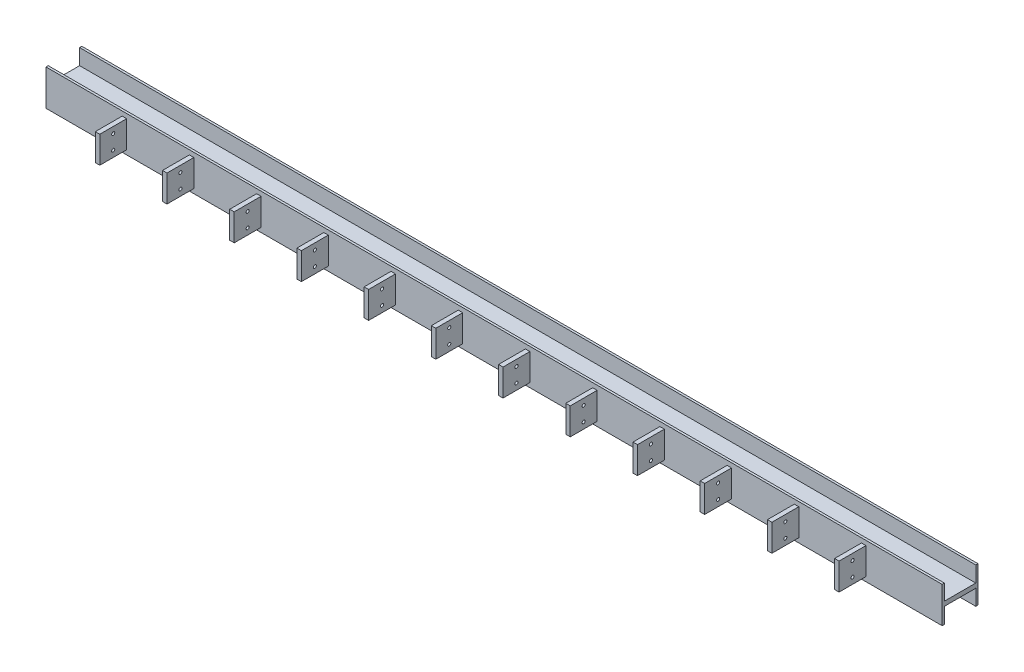
from build123d import *

# Parameters (mm, degrees)
SKETCH1_W           = 10000
SKETCH1_H           = 400
BOSS_EXTRUDE1_DEPTH = 400
SKETCH2_W           = 350
SKETCH2_H           = 175
CUT_EXTRUDE1_DEPTH  = 10100
SKETCH3_W           = 50
SKETCH3_H           = 300
BOSS_EXTRUDE2_DEPTH = 300
SKETCH4_R           = 17.5
CUT_EXTRUDE2_DEPTH  = 8530


with BuildPart() as part:
    # Sketch1 → Boss-Extrude1 (new body)
    with BuildSketch(Plane.XY):
        Rectangle(SKETCH1_W, SKETCH1_H)
    extrude(amount=BOSS_EXTRUDE1_DEPTH)

    # Sketch2 → Cut-Extrude1 (cut)
    with BuildSketch(Plane(origin=(5000, 0, 0), x_dir=(0, 0, -1), z_dir=(1, 0, 0))):
        with Locations((-200, 112.5)):
            Rectangle(SKETCH2_W, SKETCH2_H)
        with Locations((-200, -112.5)):
            Rectangle(SKETCH2_W, SKETCH2_H)
    extrude(amount=-CUT_EXTRUDE1_DEPTH, mode=Mode.SUBTRACT)

    # Sketch3 → Boss-Extrude2 (add)
    with BuildSketch(Plane.XY.offset(400)):
        with Locations((-3375, 0)):
            Rectangle(SKETCH3_W, SKETCH3_H)
        with Locations((-4125, 0)):
            Rectangle(SKETCH3_W, SKETCH3_H)
        with Locations((-2625, 0)):
            Rectangle(SKETCH3_W, SKETCH3_H)
        with Locations((-1875, 0)):
            Rectangle(SKETCH3_W, SKETCH3_H)
        with Locations((-1125, 0)):
            Rectangle(SKETCH3_W, SKETCH3_H)
        with Locations((-375, 0)):
            Rectangle(SKETCH3_W, SKETCH3_H)
        with Locations((375, 0)):
            Rectangle(SKETCH3_W, SKETCH3_H)
        with Locations((1125, 0)):
            Rectangle(SKETCH3_W, SKETCH3_H)
        with Locations((1875, 0)):
            Rectangle(SKETCH3_W, SKETCH3_H)
        with Locations((2625, 0)):
            Rectangle(SKETCH3_W, SKETCH3_H)
        with Locations((3375, 0)):
            Rectangle(SKETCH3_W, SKETCH3_H)
        with Locations((4125, 0)):
            Rectangle(SKETCH3_W, SKETCH3_H)
    extrude(amount=BOSS_EXTRUDE2_DEPTH)

    # Sketch4 → Cut-Extrude2 (cut)
    with BuildSketch(Plane(origin=(4150, 0, 0), x_dir=(0, 0, -1), z_dir=(1, 0, 0))):
        with Locations((-550, 80)):
            Circle(SKETCH4_R)
        with Locations((-550, -80)):
            Circle(SKETCH4_R)
    extrude(amount=-CUT_EXTRUDE2_DEPTH, mode=Mode.SUBTRACT)


solid = part.part
